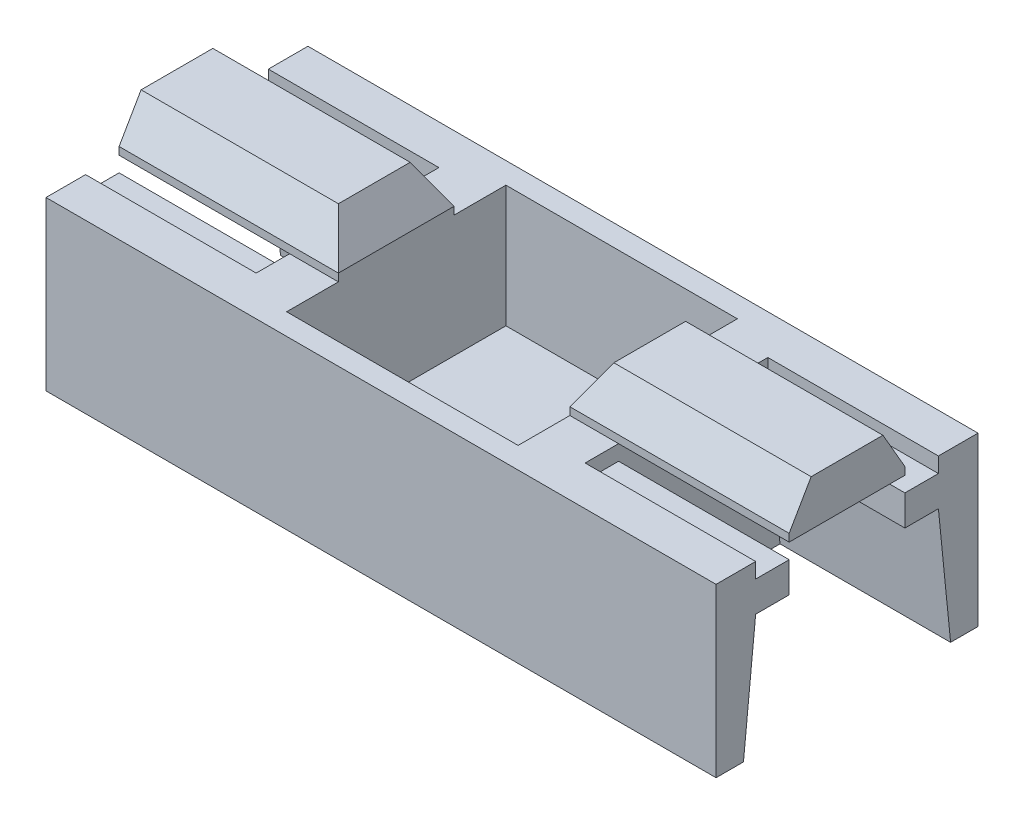
from build123d import *

# Parameters (mm, degrees)
ESQUISSE1_W             = 22
ESQUISSE1_H             = 7
BOSS_EXTRU_1_DEPTH      = 8.6
ESQUISSE2_W             = 7.6
ESQUISSE2_H             = 7.2
ENL_V_MAT_EXTRU_1_DEPTH = 5.5
ESQUISSE3_W             = 2.4
ESQUISSE3_H             = 1.5
ENL_V_MAT_EXTRU_2_DEPTH = 23
ENL_V_MAT_EXTRU_5_DEPTH = 5.6
CHANFREIN1_SIZE         = 1.25
CHANFREIN1_SIZE2        = 0.721687836
CHANFREIN1_PART_2_SIZE  = 1.25
CHANFREIN1_PART_2_SIZE2 = 0.721687836
CHANFREIN1_PART_3_SIZE  = 1.25
CHANFREIN1_PART_3_SIZE2 = 0.721687836
CHANFREIN2_SIZE         = 1.25
CHANFREIN2_SIZE2        = 0.721687836
CHANFREIN2_PART_2_SIZE  = 1.25
CHANFREIN2_PART_2_SIZE2 = 0.721687836
CHANFREIN2_PART_3_SIZE  = 1.25
CHANFREIN2_PART_3_SIZE2 = 0.721687836


with BuildPart() as part:
    # Esquisse1 → Boss.-Extru.1 (new body)
    with BuildSketch(Plane.XY):
        with Locations((11, 3.5)):
            Rectangle(ESQUISSE1_W, ESQUISSE1_H)
    extrude(amount=BOSS_EXTRU_1_DEPTH)

    # Esquisse2 → Enlèv. mat.-Extru.1 (cut)
    with BuildSketch(Plane(origin=(0, 7, 0), x_dir=(1, 0, 0), z_dir=(0, 1, 0))):
        with Locations((11, -4.3)):
            Rectangle(ESQUISSE2_W, ESQUISSE2_H)
    extrude(amount=-ENL_V_MAT_EXTRU_1_DEPTH, mode=Mode.SUBTRACT)

    # Esquisse3 → Enlèv. mat.-Extru.2 (cut, through all)
    with BuildSketch(Plane(origin=(22, 0, 0), x_dir=(0, 0, -1), z_dir=(1, 0, 0))):
        with Locations((-1.2, 6.25)):
            Rectangle(ESQUISSE3_W, ESQUISSE3_H)
        with Locations((-7.4, 6.25)):
            Rectangle(ESQUISSE3_W, ESQUISSE3_H)
    extrude(amount=-ENL_V_MAT_EXTRU_2_DEPTH, mode=Mode.SUBTRACT)

    # Esquisse6 → Enlèv. mat.-Extru.5 (cut)
    with BuildSketch(Plane(origin=(22, 0, 0), x_dir=(0, 0, -1), z_dir=(1, 0, 0))):
        Polygon((-1.3, 5.5), (-7.3, 5.5), (-7.3, 5), (-6.2, 5), (-6.2, 4), (-7.3, 4), (-7.7, 0), (-0.9, 0), (-1.3, 4), (-2.4, 4), (-2.4, 5), (-1.3, 5), align=None)
    enl_v_mat_extru_5 = extrude(amount=-ENL_V_MAT_EXTRU_5_DEPTH, mode=Mode.SUBTRACT)

    # Chanfrein1
    chanfrein1_edges = [part.edges().sort_by_distance(p)[0] for p in [
        (14.8, 7, 4.3),
    ]]
    chanfrein1_side = [part.faces().sort_by_distance(p)[0] for p in [
        (14.8, 3.954347826, 4.3),
    ]]
    chamfer(chanfrein1_edges, length=CHANFREIN1_SIZE, length2=CHANFREIN1_SIZE2, reference=chanfrein1_side[0])

    # Chanfrein1 part 2
    chanfrein1_part_2_edges = [part.edges().sort_by_distance(p)[0] for p in [
        (18.4, 7, 6.2),
    ]]
    chanfrein1_part_2_side = [part.faces().sort_by_distance(p)[0] for p in [
        (18.4, 6.25, 6.2),
    ]]
    chamfer(chanfrein1_part_2_edges, length=CHANFREIN1_PART_2_SIZE, length2=CHANFREIN1_PART_2_SIZE2, reference=chanfrein1_part_2_side[0])

    # Chanfrein1 part 3
    chanfrein1_part_3_edges = [part.edges().sort_by_distance(p)[0] for p in [
        (18.4, 7, 2.4),
    ]]
    chanfrein1_part_3_side = [part.faces().sort_by_distance(p)[0] for p in [
        (18.4, 6.25, 2.4),
    ]]
    chamfer(chanfrein1_part_3_edges, length=CHANFREIN1_PART_3_SIZE, length2=CHANFREIN1_PART_3_SIZE2, reference=chanfrein1_part_3_side[0])

    # Symétrie4: Enlèv. mat.-Extru.5 across plane
    add(enl_v_mat_extru_5.mirror(Plane(origin=(11, 0, 0), x_dir=(0, 0, 1), z_dir=(1, 0, 0))), mode=Mode.SUBTRACT)

    # Chanfrein2
    chanfrein2_edges = [part.edges().sort_by_distance(p)[0] for p in [
        (3.6, 7, 6.2),
    ]]
    chanfrein2_side = [part.faces().sort_by_distance(p)[0] for p in [
        (3.6, 6.25, 6.2),
    ]]
    chamfer(chanfrein2_edges, length=CHANFREIN2_SIZE, length2=CHANFREIN2_SIZE2, reference=chanfrein2_side[0])

    # Chanfrein2 part 2
    chanfrein2_part_2_edges = [part.edges().sort_by_distance(p)[0] for p in [
        (7.2, 7, 4.3),
    ]]
    chanfrein2_part_2_side = [part.faces().sort_by_distance(p)[0] for p in [
        (7.2, 3.954347826, 4.3),
    ]]
    chamfer(chanfrein2_part_2_edges, length=CHANFREIN2_PART_2_SIZE, length2=CHANFREIN2_PART_2_SIZE2, reference=chanfrein2_part_2_side[0])

    # Chanfrein2 part 3
    chanfrein2_part_3_edges = [part.edges().sort_by_distance(p)[0] for p in [
        (3.6, 7, 2.4),
    ]]
    chanfrein2_part_3_side = [part.faces().sort_by_distance(p)[0] for p in [
        (3.6, 6.25, 2.4),
    ]]
    chamfer(chanfrein2_part_3_edges, length=CHANFREIN2_PART_3_SIZE, length2=CHANFREIN2_PART_3_SIZE2, reference=chanfrein2_part_3_side[0])


solid = part.part
